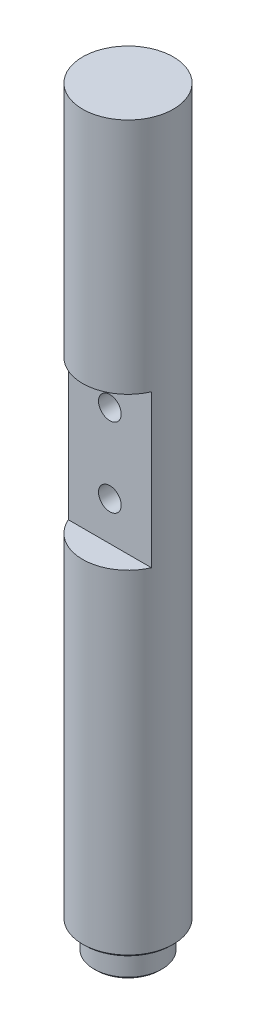
from build123d import *

# Parameters (mm, degrees)
SKETCH1_R               = 12.7
BOSS_EXTRUDE1_DEPTH     = 203.2
SKETCH2_R               = 9.525
BOSS_EXTRUDE2_DEPTH     = 7.62
CHAMFER1_SIZE           = 0.635
CUT_EXTRUDE1_DEPTH      = 25.4
CUT_EXTRUDE1_DEPTH_BACK = 25.4
SKETCH4_W               = 7.62
SKETCH4_H               = 42.672
SKETCH5_R               = 3.175
CUT_EXTRUDE2_DEPTH      = 25.4


with BuildPart() as part:
    # Sketch1 → Boss-Extrude1 (new body)
    with BuildSketch(Plane(origin=(0, 0, 0), x_dir=(1, 0, 0), z_dir=(0, 1, 0))):
        Circle(SKETCH1_R)
    extrude(amount=BOSS_EXTRUDE1_DEPTH)

    # Sketch2 → Boss-Extrude2 (add)
    with BuildSketch(Plane(origin=(0, 0, 0), x_dir=(-1, 0, 0), z_dir=(0, -1, 0))):
        Circle(SKETCH2_R)
    extrude(amount=BOSS_EXTRUDE2_DEPTH)

    # Chamfer1
    chamfer1_edges = [part.edges().sort_by_distance(p)[0] for p in [
        (-12.7, 0, 0),
        (9.525, -7.62, 0),
    ]]
    chamfer(chamfer1_edges, length=CHAMFER1_SIZE)

    # Sketch4 → Cut-Extrude1 (cut, two sides: drawn at the far end of the back side and taken through both)
    with BuildSketch(Plane(origin=(0, 0, 0), x_dir=(0, 0, -1), z_dir=(1, 0, 0)).offset(-CUT_EXTRUDE1_DEPTH_BACK)):
        with Locations((-8.89, 115.316)):
            Rectangle(SKETCH4_W, SKETCH4_H)
    extrude(amount=CUT_EXTRUDE1_DEPTH + CUT_EXTRUDE1_DEPTH_BACK, mode=Mode.SUBTRACT)

    # Sketch5 → Cut-Extrude2 (cut)
    with BuildSketch(Plane.XY.offset(5.08)):
        with Locations((0, 104.902)):
            Circle(SKETCH5_R)
        with Locations((0, 127)):
            Circle(SKETCH5_R)
    extrude(amount=-CUT_EXTRUDE2_DEPTH, mode=Mode.SUBTRACT)


solid = part.part
